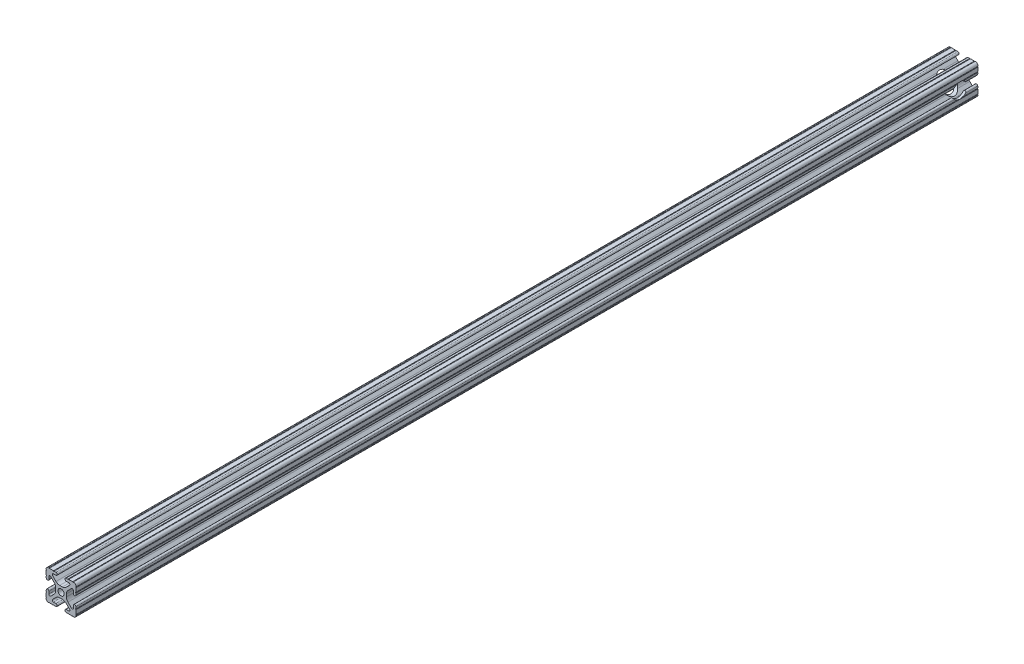
from build123d import *

# Parameters (mm, degrees)
SKETCH3_R               = 2.6035
EXTRUDE1_DEPTH          = 380
SKETCH5_R               = 6.35
CUT_EXTRUDE2_DEPTH      = 9.1915
CUT_EXTRUDE2_DEPTH_BACK = 18.2085


with BuildPart() as part:
    # Sketch3 → Extrude1 (new body, symmetric)
    with BuildSketch(Plane.XY):
        with BuildLine():
            Line((-1.115277175, 4.5085), (1.115277175, 4.5085))
            ThreePointArc((1.115277175, 4.5085), (2.806584872, 4.844922018), (4.240406305, 5.80297087))
            Line((4.240406305, 5.80297087), (7.148423664, 8.710988229))
            ThreePointArc((7.148423664, 8.710988229), (7.349906316, 9.772227925), (6.436353897, 10.348636575))
            Line((6.436353897, 10.348636575), (4.381960454, 10.276895575))
            ThreePointArc((4.381960454, 10.276895575), (3.239173075, 11.342562046), (4.304839546, 12.485349424))
            Line((4.304839546, 12.485349424), (5.728246175, 12.535055879))
            ThreePointArc((5.728246175, 12.535055879), (6.054756855, 12.230579745), (6.35923299, 12.557090424))
            Line((6.35923299, 12.557090424), (9.782092278, 12.676619304))
            ThreePointArc((9.782092278, 12.676619304), (10.108602958, 12.37214317), (10.413079092, 12.69865385))
            ThreePointArc((10.413079092, 12.69865385), (12.052764565, 12.052764565), (12.69865385, 10.413079092))
            ThreePointArc((12.69865385, 10.413079092), (12.37214317, 10.108602958), (12.676619304, 9.782092278))
            Line((12.676619304, 9.782092278), (12.557090424, 6.35923299))
            ThreePointArc((12.557090424, 6.35923299), (12.230579745, 6.054756855), (12.535055879, 5.728246175))
            Line((12.535055879, 5.728246175), (12.485349424, 4.304839546))
            ThreePointArc((12.485349424, 4.304839546), (11.342562046, 3.239173075), (10.276895575, 4.381960454))
            Line((10.276895575, 4.381960454), (10.348636575, 6.436353897))
            ThreePointArc((10.348636575, 6.436353897), (9.772227925, 7.349906316), (8.710988229, 7.148423664))
            Line((8.710988229, 7.148423664), (5.80297087, 4.240406305))
            ThreePointArc((5.80297087, 4.240406305), (4.844922018, 2.806584872), (4.5085, 1.115277175))
            Line((4.5085, 1.115277175), (4.5085, -1.115277175))
            ThreePointArc((4.5085, -1.115277175), (4.844922018, -2.806584872), (5.80297087, -4.240406305))
            Line((5.80297087, -4.240406305), (8.710988229, -7.148423664))
            ThreePointArc((8.710988229, -7.148423664), (9.772227925, -7.349906316), (10.348636575, -6.436353897))
            Line((10.348636575, -6.436353897), (10.276895575, -4.381960454))
            ThreePointArc((10.276895575, -4.381960454), (11.342562046, -3.239173075), (12.485349424, -4.304839546))
            Line((12.485349424, -4.304839546), (12.535055879, -5.728246175))
            ThreePointArc((12.535055879, -5.728246175), (12.230579745, -6.054756855), (12.557090424, -6.35923299))
            Line((12.557090424, -6.35923299), (12.676619304, -9.782092278))
            ThreePointArc((12.676619304, -9.782092278), (12.37214317, -10.108602958), (12.69865385, -10.413079092))
            ThreePointArc((12.69865385, -10.413079092), (12.052764565, -12.052764565), (10.413079092, -12.69865385))
            ThreePointArc((10.413079092, -12.69865385), (10.108602958, -12.37214317), (9.782092278, -12.676619304))
            Line((9.782092278, -12.676619304), (6.35923299, -12.557090424))
            ThreePointArc((6.35923299, -12.557090424), (6.054756855, -12.230579745), (5.728246175, -12.535055879))
            Line((5.728246175, -12.535055879), (4.304839546, -12.485349424))
            ThreePointArc((4.304839546, -12.485349424), (3.239173075, -11.342562046), (4.381960454, -10.276895575))
            Line((4.381960454, -10.276895575), (6.436353897, -10.348636575))
            ThreePointArc((6.436353897, -10.348636575), (7.349906316, -9.772227925), (7.148423664, -8.710988229))
            Line((7.148423664, -8.710988229), (4.240406305, -5.80297087))
            ThreePointArc((4.240406305, -5.80297087), (2.806584872, -4.844922018), (1.115277175, -4.5085))
            Line((1.115277175, -4.5085), (-1.115277175, -4.5085))
            ThreePointArc((-1.115277175, -4.5085), (-2.806584872, -4.844922018), (-4.240406305, -5.80297087))
            Line((-4.240406305, -5.80297087), (-7.148423664, -8.710988229))
            ThreePointArc((-7.148423664, -8.710988229), (-7.349906316, -9.772227925), (-6.436353897, -10.348636575))
            Line((-6.436353897, -10.348636575), (-4.381960454, -10.276895575))
            ThreePointArc((-4.381960454, -10.276895575), (-3.239173075, -11.342562046), (-4.304839546, -12.485349424))
            Line((-4.304839546, -12.485349424), (-5.728246175, -12.535055879))
            ThreePointArc((-5.728246175, -12.535055879), (-6.054756855, -12.230579745), (-6.35923299, -12.557090424))
            Line((-6.35923299, -12.557090424), (-9.782092278, -12.676619304))
            ThreePointArc((-9.782092278, -12.676619304), (-10.108602958, -12.37214317), (-10.413079092, -12.69865385))
            ThreePointArc((-10.413079092, -12.69865385), (-12.052764565, -12.052764565), (-12.69865385, -10.413079092))
            ThreePointArc((-12.69865385, -10.413079092), (-12.37214317, -10.108602958), (-12.676619304, -9.782092278))
            Line((-12.676619304, -9.782092278), (-12.557090424, -6.35923299))
            ThreePointArc((-12.557090424, -6.35923299), (-12.230579745, -6.054756855), (-12.535055879, -5.728246175))
            Line((-12.535055879, -5.728246175), (-12.485349424, -4.304839546))
            ThreePointArc((-12.485349424, -4.304839546), (-11.342562046, -3.239173075), (-10.276895575, -4.381960454))
            Line((-10.276895575, -4.381960454), (-10.348636575, -6.436353897))
            ThreePointArc((-10.348636575, -6.436353897), (-9.772227925, -7.349906316), (-8.710988229, -7.148423664))
            Line((-8.710988229, -7.148423664), (-5.80297087, -4.240406305))
            ThreePointArc((-5.80297087, -4.240406305), (-4.844922018, -2.806584872), (-4.5085, -1.115277175))
            Line((-4.5085, -1.115277175), (-4.5085, 1.115277175))
            ThreePointArc((-4.5085, 1.115277175), (-4.844922018, 2.806584872), (-5.80297087, 4.240406305))
            Line((-5.80297087, 4.240406305), (-8.710988229, 7.148423664))
            ThreePointArc((-8.710988229, 7.148423664), (-9.772227925, 7.349906316), (-10.348636575, 6.436353897))
            Line((-10.348636575, 6.436353897), (-10.276895575, 4.381960454))
            ThreePointArc((-10.276895575, 4.381960454), (-11.342562046, 3.239173075), (-12.485349424, 4.304839546))
            Line((-12.485349424, 4.304839546), (-12.535055879, 5.728246175))
            ThreePointArc((-12.535055879, 5.728246175), (-12.230579745, 6.054756855), (-12.557090424, 6.35923299))
            Line((-12.557090424, 6.35923299), (-12.676619304, 9.782092278))
            ThreePointArc((-12.676619304, 9.782092278), (-12.37214317, 10.108602958), (-12.69865385, 10.413079092))
            ThreePointArc((-12.69865385, 10.413079092), (-12.052764565, 12.052764565), (-10.413079092, 12.69865385))
            ThreePointArc((-10.413079092, 12.69865385), (-10.108602958, 12.37214317), (-9.782092278, 12.676619304))
            Line((-9.782092278, 12.676619304), (-6.35923299, 12.557090424))
            ThreePointArc((-6.35923299, 12.557090424), (-6.054756855, 12.230579745), (-5.728246175, 12.535055879))
            Line((-5.728246175, 12.535055879), (-4.304839546, 12.485349424))
            ThreePointArc((-4.304839546, 12.485349424), (-3.239173075, 11.342562046), (-4.381960454, 10.276895575))
            Line((-4.381960454, 10.276895575), (-6.436353897, 10.348636575))
            ThreePointArc((-6.436353897, 10.348636575), (-7.349906316, 9.772227925), (-7.148423664, 8.710988229))
            Line((-7.148423664, 8.710988229), (-4.240406305, 5.80297087))
            ThreePointArc((-4.240406305, 5.80297087), (-2.806584872, 4.844922018), (-1.115277175, 4.5085))
        make_face()
        Circle(SKETCH3_R, mode=Mode.SUBTRACT)
    extrude(amount=EXTRUDE1_DEPTH, both=True)

    # Sketch5 → Cut-Extrude2 (cut, two sides)
    with BuildSketch(Plane(origin=(4.5085, 0, 0), x_dir=(0, 0, -1), z_dir=(1, 0, 0))) as cut_extrude2_sk:
        with Locations((365, 0)):
            Circle(SKETCH5_R)
    extrude(amount=CUT_EXTRUDE2_DEPTH, mode=Mode.SUBTRACT)
    extrude(cut_extrude2_sk.sketch, amount=-CUT_EXTRUDE2_DEPTH_BACK, mode=Mode.SUBTRACT)


solid = part.part
